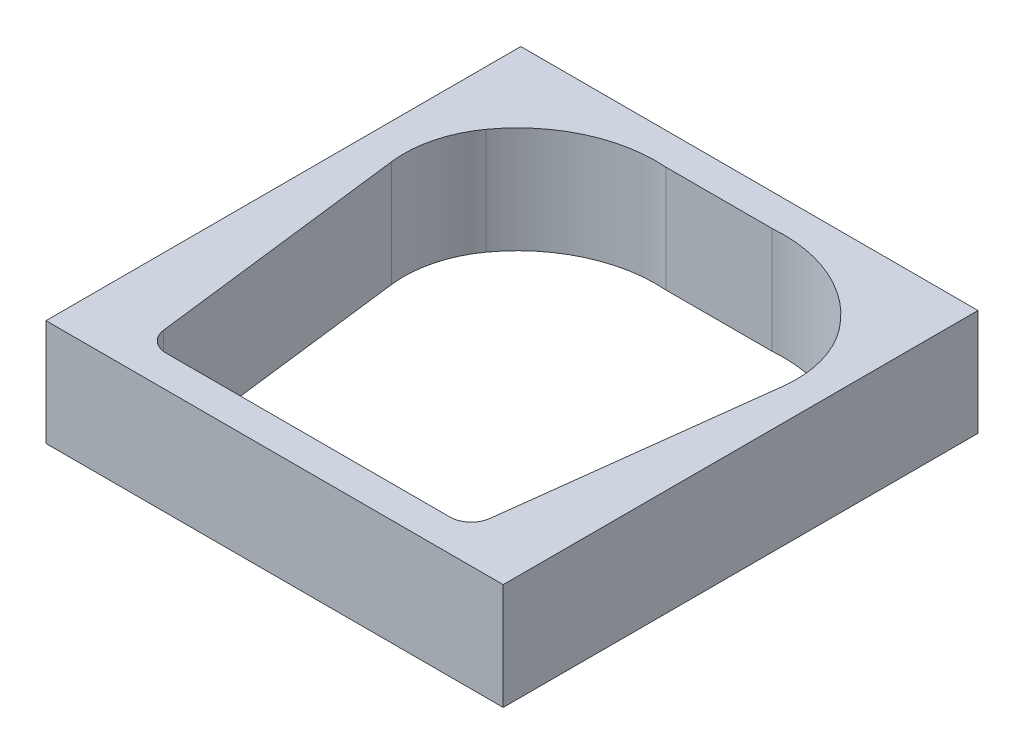
from build123d import *

# Parameters (mm, degrees)
BOSS_EXTRUDE1_DEPTH     = 2133.6
SKETCH2_W               = 42.970576624
SKETCH2_H               = 44.626294369
BOSS_EXTRUDE2_DEPTH     = 10
CUT_EXTRUDE1_DEPTH      = 2134.6
CUT_EXTRUDE1_DEPTH_BACK = 1


with BuildPart() as part:
    # Sketch1 → Boss-Extrude1 (new body)
    with BuildSketch(Plane(origin=(0, 0, 0), x_dir=(1, 0, 0), z_dir=(0, 1, 0))):
        with BuildLine():
            Line((13.630161568, 10), (23.630161568, 10))
            ThreePointArc((23.630161568, 10), (29.962715696, 8.909575546), (34.999417241, 4.919349386))
            ThreePointArc((34.999417241, 4.919349386), (36.697471107, 1.472711464), (36.970576624, -2.359795976))
            Line((36.970576624, -2.359795976), (33.961097926, -26.870033055))
            ThreePointArc((33.961097926, -26.870033055), (33.301245719, -28.12420581), (31.976005623, -28.626294369))
            Line((31.976005623, -28.626294369), (5.284317513, -28.626294369))
            ThreePointArc((5.284317513, -28.626294369), (3.959077417, -28.12420581), (3.29922521, -26.870033055))
            Line((3.29922521, -26.870033055), (0.298191514, -2.428574989))
            ThreePointArc((0.298191514, -2.428574989), (0.53721959, 1.274672171), (2.110183266, 4.635767116))
            ThreePointArc((2.110183266, 4.635767116), (7.170061398, 8.821409583), (13.630161568, 10))
        make_face()
    extrude(amount=BOSS_EXTRUDE1_DEPTH)

    # Sketch2 → Boss-Extrude2 (add)
    with BuildSketch(Plane(origin=(0, 0, 0), x_dir=(1, 0, 0), z_dir=(0, 1, 0))):
        with Locations((18.485288312, -9.313147185)):
            Rectangle(SKETCH2_W, SKETCH2_H)
    extrude(amount=BOSS_EXTRUDE2_DEPTH)

    # Sketch3 → Cut-Extrude1 (cut, two sides)
    with BuildSketch(Plane(origin=(0, 0, 0), x_dir=(1, 0, 0), z_dir=(0, 1, 0))) as cut_extrude1_sk:
        with BuildLine():
            Line((0.298191514, -2.428574989), (3.29922521, -26.870033055))
            ThreePointArc((3.29922521, -26.870033055), (3.959077417, -28.12420581), (5.284317513, -28.626294369))
            Line((5.284317513, -28.626294369), (31.976005623, -28.626294369))
            ThreePointArc((31.976005623, -28.626294369), (33.301245719, -28.12420581), (33.961097926, -26.870033055))
            Line((33.961097926, -26.870033055), (36.970576624, -2.359795976))
            ThreePointArc((36.970576624, -2.359795976), (36.697471107, 1.472711464), (34.999417241, 4.919349386))
            ThreePointArc((34.999417241, 4.919349386), (29.962715696, 8.909575546), (23.630161568, 10))
            Line((23.630161568, 10), (13.630161568, 10))
            ThreePointArc((13.630161568, 10), (7.170061398, 8.821409583), (2.110183266, 4.635767116))
            ThreePointArc((2.110183266, 4.635767116), (0.53721959, 1.274672171), (0.298191514, -2.428574989))
        make_face()
    extrude(amount=CUT_EXTRUDE1_DEPTH, mode=Mode.SUBTRACT)
    extrude(cut_extrude1_sk.sketch, amount=-CUT_EXTRUDE1_DEPTH_BACK, mode=Mode.SUBTRACT)


solid = part.part
